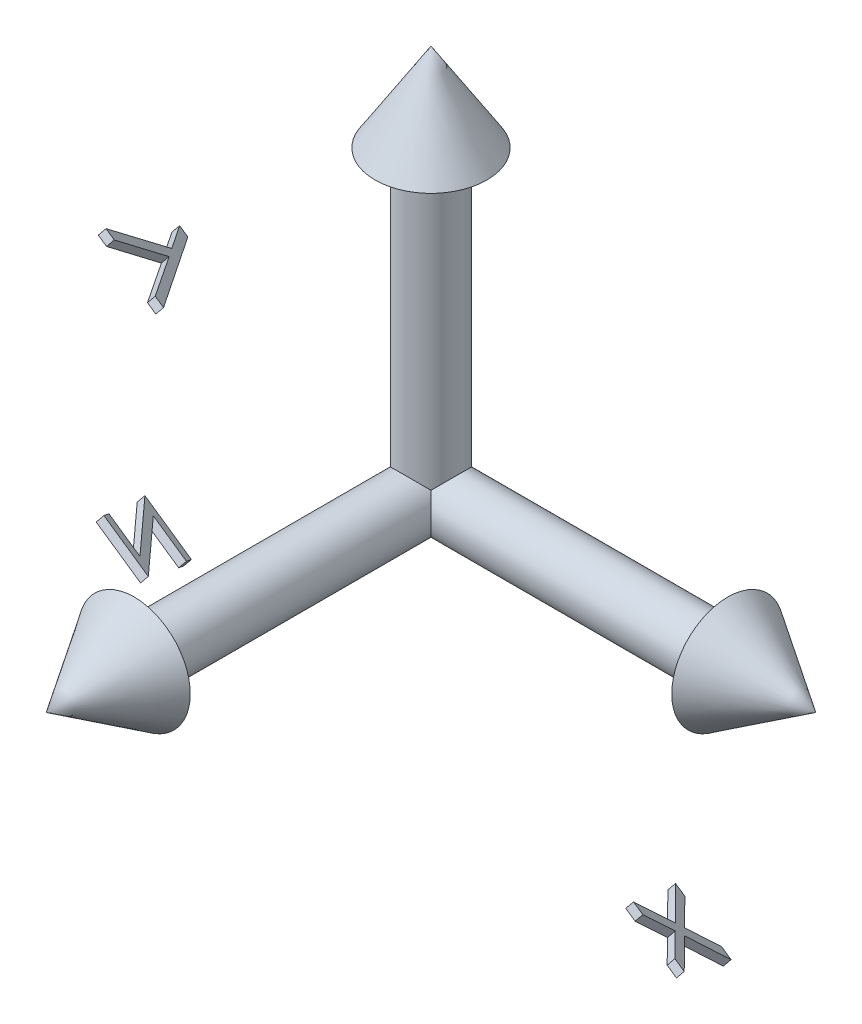
from build123d import *

# Parameters (mm, degrees)
BODY_MOVE_COPY1_ANGLE = 90
BODY_MOVE_COPY2_ANGLE = 90
BOSS_EXTRUDE1_DEPTH   = 1
BOSS_EXTRUDE1_2_DEPTH = 1
BOSS_EXTRUDE1_3_DEPTH = 1


with BuildPart() as part:
    # Sketch3 → Revolve1 (revolve)
    with BuildSketch(Plane(origin=(0, 0, 0), x_dir=(1, 0, 0), z_dir=(0, 1, 0)), mode=Mode.PRIVATE) as revolve1_sk:
        Polygon((0, 0), (0, -3.645895919), (37.591185407, -3.645895919), (37.591185407, -7.09114457), (48.747430917, 0), align=None)
    revolve(revolve1_sk.sketch.rotate(Axis((48.747430917, 0, 0), (-1, 0, 0)), 180), axis=Axis((48.747430917, 0, 0), (-1, 0, 0)))


with BuildPart() as body_2:
    # Body-Move/Copy1: copy of part
    add(part.part.rotate(Axis((0, 0, 0), (0, -1, 0)), BODY_MOVE_COPY1_ANGLE))


with BuildPart() as body_3:
    # Body-Move/Copy2: copy of part
    add(part.part.rotate(Axis((0, 0, 0), (0, 0, 1)), BODY_MOVE_COPY2_ANGLE))


with BuildPart() as body_4:
    # Sketch4 → Boss-Extrude1 (new body)
    with BuildSketch(Plane(origin=(0, 0, 0), x_dir=(-0.8666285170524558, 0.4153545531538273, -0.2764699054252484), z_dir=(-0.4989539191463089, -0.7214255397904507, 0.4801980602903302))):
        Polygon((-46.00237026, -1.796273994), (-47.365992055, -1.340885372), (-48.607498465, 2.711818954), (-52.036905517, 0.223717993), (-53.397983241, 0.679106615), (-48.97893276, 3.861738826), (-50.828472023, 9.629146679), (-49.449585805, 9.168669916), (-47.989289331, 4.558814147), (-44.089229235, 7.375100204), (-42.735783722, 6.922255653), (-47.625487248, 3.408894275), align=None)
    extrude(amount=BOSS_EXTRUDE1_DEPTH)


with BuildPart() as body_5:
    # Sketch4 → Boss-Extrude1 2 (new body)
    with BuildSketch(Plane(origin=(0, 0, 0), x_dir=(-0.8666285170524558, 0.4153545531538273, -0.2764699054252484), z_dir=(-0.4989539191463089, -0.7214255397904507, 0.4801980602903302))):
        Polygon((-10.827706758, -57.451779744), (-17.304910284, -55.286775737), (-9.69559538, -49.137757308), (-14.529329355, -47.522272532), (-14.193512047, -46.51736468), (-7.405931919, -48.786675577), (-15.017790893, -54.943326218), (-10.494433521, -56.454504103), align=None)
    extrude(amount=BOSS_EXTRUDE1_2_DEPTH)


with BuildPart() as body_6:
    # Sketch4 → Boss-Extrude1 3 (new body)
    with BuildSketch(Plane(origin=(0, 0, 0), x_dir=(-0.8666285170524558, 0.4153545531538273, -0.2764699054252484), z_dir=(-0.4989539191463089, -0.7214255397904507, 0.4801980602903302))):
        Polygon((24.619624365, -32.00316483), (23.418823083, -31.601201689), (22.658145999, -23.790905215), (17.442801448, -29.601562266), (16.234367955, -29.197055055), (25.527857538, -18.90628983), (26.72865882, -19.308252971), (23.724111544, -22.630809061), align=None)
    extrude(amount=BOSS_EXTRUDE1_3_DEPTH)


solid = Compound([part.part, body_2.part, body_3.part, body_4.part, body_5.part, body_6.part])
